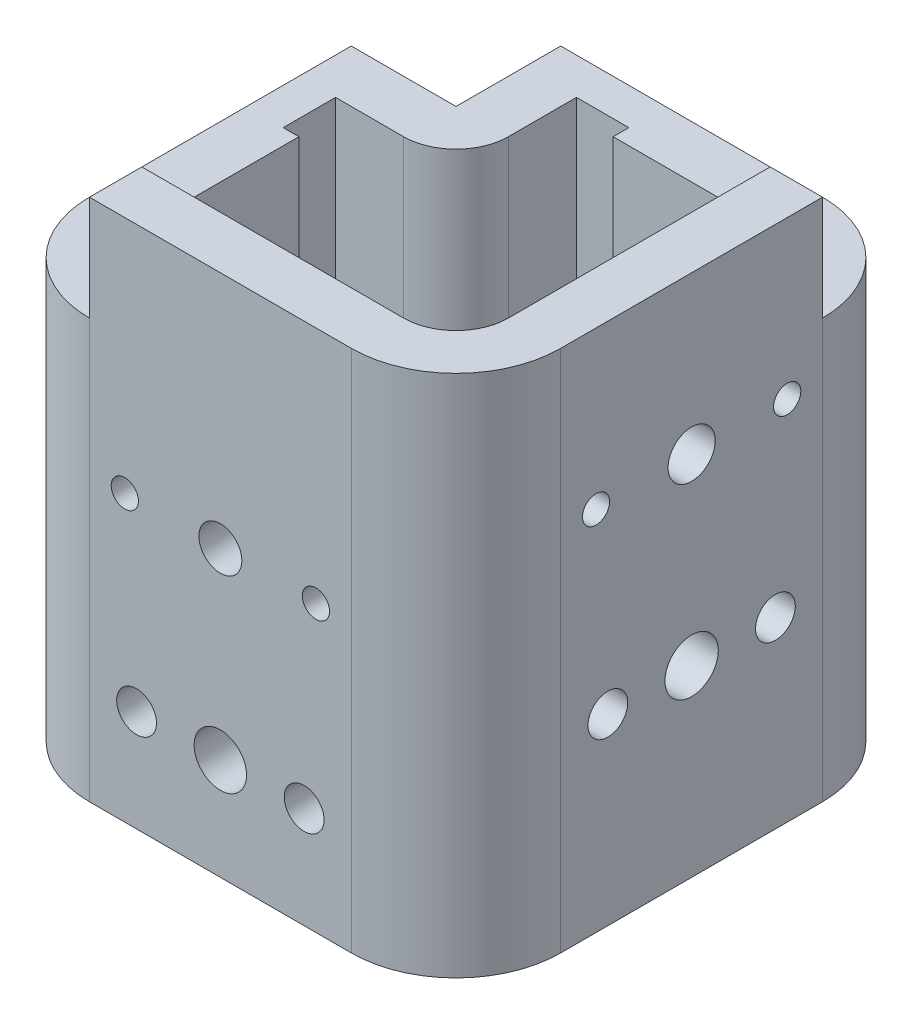
from build123d import *

# Parameters (mm, degrees)
BOSS_EXTRUDE1_DEPTH      = 30
BOSS_EXTRUDE1_DEPTH_BACK = 70
CUT_EXTRUDE1_REACH       = 92
SKETCH2_R                = 4.5
SKETCH2_R_2              = 5.1
SKETCH2_R_3              = 3.8
SKETCH5_W                = 20
SKETCH5_H                = 20
CUT_EXTRUDE2_DEPTH       = 91
CUT_EXTRUDE3_REACH       = 92
SKETCH7_W                = 20
SKETCH7_H                = 20
SKETCH8_R                = 5
SKETCH8_R_2              = 4.1
SKETCH8_R_3              = 3.8
CUT_EXTRUDE6_DEPTH       = 10
SKETCH9_W                = 20
SKETCH9_H                = 20
SKETCH9_W_2              = 3
SKETCH9_H_2              = 3
CUT_EXTRUDE7_DEPTH       = 81
BOSS_EXTRUDE2_DEPTH      = 80


with BuildPart() as part:
    # Sketch1 → Boss-Extrude1 (new body, two sides)
    with BuildSketch(Plane(origin=(0, 0, 0), x_dir=(1, 0, 0), z_dir=(0, 1, 0))) as boss_extrude1_sk:
        with BuildLine():
            Line((-25, 45), (25, 45))
            ThreePointArc((25, 45), (39.142135624, 39.142135624), (45, 25))
            Line((45, 25), (45, -25))
            ThreePointArc((45, -25), (39.142135624, -39.142135624), (25, -45))
            Line((25, -45), (-25, -45))
            ThreePointArc((-25, -45), (-39.142135624, -39.142135624), (-45, -25))
            Line((-45, -25), (-45, 25))
            ThreePointArc((-45, 25), (-39.142135624, 39.142135624), (-25, 45))
        make_face()
        with BuildLine():
            Line((-25, 35), (25, 35))
            ThreePointArc((25, 35), (32.071067812, 32.071067812), (35, 25))
            Line((35, 25), (35, -25))
            ThreePointArc((35, -25), (32.071067812, -32.071067812), (25, -35))
            Line((25, -35), (-25, -35))
            ThreePointArc((-25, -35), (-32.071067812, -32.071067812), (-35, -25))
            Line((-35, -25), (-35, 25))
            ThreePointArc((-35, 25), (-32.071067812, 32.071067812), (-25, 35))
        make_face(mode=Mode.SUBTRACT)
    extrude(amount=BOSS_EXTRUDE1_DEPTH)
    extrude(boss_extrude1_sk.sketch, amount=-BOSS_EXTRUDE1_DEPTH_BACK)

    # Sketch2 → Cut-Extrude1 (cut, up to next)
    with BuildSketch(Plane(origin=(45, 0, 0), x_dir=(0, 0, -1), z_dir=(1, 0, 0)), mode=Mode.PRIVATE) as cut_extrude1_sk1:
        with Locations((-0.001556395, 0)):
            Circle(SKETCH2_R)
    cut_extrude1_tool1 = extrude(cut_extrude1_sk1.sketch, amount=-CUT_EXTRUDE1_REACH, mode=Mode.PRIVATE) & part.part
    add(cut_extrude1_tool1.solids().sort_by_distance((45, 0, 0.001556))[0], mode=Mode.SUBTRACT)
    # Sketch2 → Cut-Extrude1 (cut, up to next)
    with BuildSketch(Plane(origin=(45, 0, 0), x_dir=(0, 0, -1), z_dir=(1, 0, 0)), mode=Mode.PRIVATE) as cut_extrude1_sk2:
        with Locations((-0.001556395, -35)):
            Circle(SKETCH2_R_2)
    cut_extrude1_tool2 = extrude(cut_extrude1_sk2.sketch, amount=-CUT_EXTRUDE1_REACH, mode=Mode.PRIVATE) & part.part
    add(cut_extrude1_tool2.solids().sort_by_distance((45, -35, 0.001556))[0], mode=Mode.SUBTRACT)
    # Sketch2 → Cut-Extrude1 (cut, up to next)
    with BuildSketch(Plane(origin=(45, 0, 0), x_dir=(0, 0, -1), z_dir=(1, 0, 0)), mode=Mode.PRIVATE) as cut_extrude1_sk3:
        with Locations((15.998443605, -35)):
            Circle(SKETCH2_R_3)
    cut_extrude1_tool3 = extrude(cut_extrude1_sk3.sketch, amount=-CUT_EXTRUDE1_REACH, mode=Mode.PRIVATE) & part.part
    add(cut_extrude1_tool3.solids().sort_by_distance((45, -35, -15.998444))[0], mode=Mode.SUBTRACT)
    # Sketch2 → Cut-Extrude1 (cut, up to next)
    with BuildSketch(Plane(origin=(45, 0, 0), x_dir=(0, 0, -1), z_dir=(1, 0, 0)), mode=Mode.PRIVATE) as cut_extrude1_sk4:
        with Locations((-16.001556395, -35)):
            Circle(SKETCH2_R_3)
    cut_extrude1_tool4 = extrude(cut_extrude1_sk4.sketch, amount=-CUT_EXTRUDE1_REACH, mode=Mode.PRIVATE) & part.part
    add(cut_extrude1_tool4.solids().sort_by_distance((45, -35, 16.001556))[0], mode=Mode.SUBTRACT)
    # Sketch2 → Cut-Extrude1 (cut, up to next)
    with BuildSketch(Plane(origin=(45, 0, 0), x_dir=(0, 0, -1), z_dir=(1, 0, 0)), mode=Mode.PRIVATE) as cut_extrude1_sk5:
        with BuildLine():
            ThreePointArc((20.848443603, 0), (18.248443605, 2.599999998), (15.648443602, 0))
            ThreePointArc((15.648443602, 0), (18.248443605, -2.600000003), (20.848443603, 0))
        make_face()
    cut_extrude1_tool5 = extrude(cut_extrude1_sk5.sketch, amount=-CUT_EXTRUDE1_REACH, mode=Mode.PRIVATE) & part.part
    add(cut_extrude1_tool5.solids().sort_by_distance((45, 0, -18.248444))[0], mode=Mode.SUBTRACT)
    # Sketch2 → Cut-Extrude1 (cut, up to next)
    with BuildSketch(Plane(origin=(45, 0, 0), x_dir=(0, 0, -1), z_dir=(1, 0, 0)), mode=Mode.PRIVATE) as cut_extrude1_sk6:
        with BuildLine():
            ThreePointArc((-15.651556392, 0), (-18.251556395, 2.600000003), (-20.851556393, 0))
            ThreePointArc((-20.851556393, 0), (-18.251556395, -2.599999997), (-15.651556392, 0))
        make_face()
    cut_extrude1_tool6 = extrude(cut_extrude1_sk6.sketch, amount=-CUT_EXTRUDE1_REACH, mode=Mode.PRIVATE) & part.part
    add(cut_extrude1_tool6.solids().sort_by_distance((45, 0, 18.251556))[0], mode=Mode.SUBTRACT)

    # Sketch5 → Cut-Extrude2 (cut, through all)
    with BuildSketch(Plane(origin=(45, 0, 0), x_dir=(0, 0, -1), z_dir=(1, 0, 0))):
        with Locations((35, 20)):
            Rectangle(SKETCH5_W, SKETCH5_H)
    extrude(amount=-CUT_EXTRUDE2_DEPTH, mode=Mode.SUBTRACT)

    # Sketch7 → Cut-Extrude3 (cut, up to next)
    with BuildSketch(Plane.XY.offset(45), mode=Mode.PRIVATE) as cut_extrude3_sk1:
        with Locations((-35, 20)):
            Rectangle(SKETCH7_W, SKETCH7_H)
    cut_extrude3_tool1 = extrude(cut_extrude3_sk1.sketch, amount=-CUT_EXTRUDE3_REACH, mode=Mode.PRIVATE) & part.part
    add(cut_extrude3_tool1.solids().sort_by_distance((-35, 20, 45))[0], mode=Mode.SUBTRACT)

    # Sketch8 → Cut-Extrude6 (cut)
    with BuildSketch(Plane.XY.offset(45)):
        with Locations((640, -50.6)):
            Circle(SKETCH8_R)
        with Locations((640, -15.6)):
            Circle(SKETCH8_R)
        with Locations((0, -15.6)):
            Circle(SKETCH8_R_2)
        with Locations((0, -50.6)):
            Circle(SKETCH8_R)
        with Locations((-16, -50.6)):
            Circle(SKETCH8_R_3)
        with Locations((16, -50.6)):
            Circle(SKETCH8_R_3)
        with BuildLine():
            ThreePointArc((-15.649999997, -15.6), (-18.25, -12.999999997), (-20.849999998, -15.6))
            ThreePointArc((-20.849999998, -15.6), (-18.25, -18.199999997), (-15.649999997, -15.6))
        make_face()
        with BuildLine():
            ThreePointArc((20.849999998, -15.6), (18.25, -13.000000002), (15.649999997, -15.6))
            ThreePointArc((15.649999997, -15.6), (18.25, -18.200000003), (20.849999998, -15.6))
        make_face()
    extrude(amount=-CUT_EXTRUDE6_DEPTH, mode=Mode.SUBTRACT)

    # Sketch9 → Cut-Extrude7 (cut, through all)
    with BuildSketch(Plane(origin=(0, 10, 0), x_dir=(1, 0, 0), z_dir=(0, 1, 0))):
        with Locations((-35, 35)):
            Rectangle(SKETCH9_W, SKETCH9_H)
        with Locations((-36.5, 15)):
            Rectangle(SKETCH9_W_2, SKETCH9_H)
        with Locations((-15, 36.5)):
            Rectangle(SKETCH9_W, SKETCH9_H_2)
    extrude(amount=-CUT_EXTRUDE7_DEPTH, mode=Mode.SUBTRACT)

    # Sketch10 → Boss-Extrude2 (add)
    with BuildSketch(Plane(origin=(0, 10, 0), x_dir=(1, 0, 0), z_dir=(0, 1, 0))):
        with BuildLine():
            Line((-25, 45), (-25, 25))
            Line((-25, 25), (-45, 25))
            Line((-45, 25), (-45, 15))
            Line((-45, 15), (-25, 15))
            ThreePointArc((-25, 15), (-17.928932188, 17.928932188), (-15, 25))
            Line((-15, 25), (-15, 45))
            Line((-15, 45), (-25, 45))
        make_face()
    extrude(amount=-BOSS_EXTRUDE2_DEPTH)


solid = part.part
